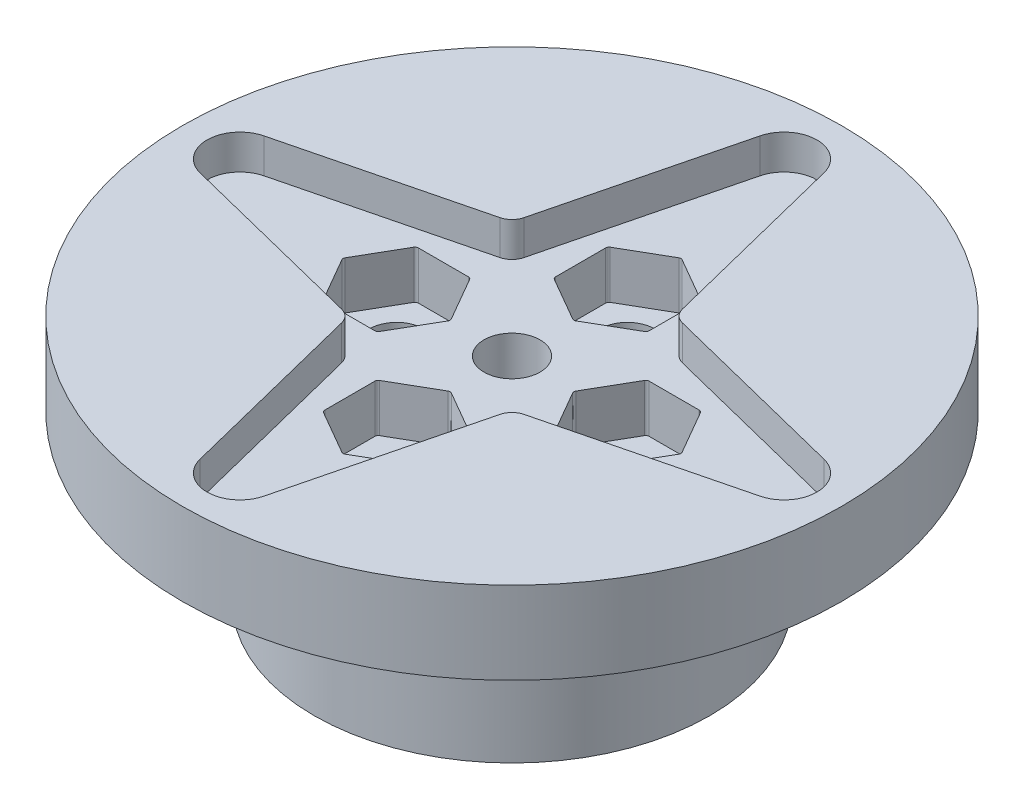
from build123d import *

# Parameters (mm, degrees)
SKETCH1_R                                       = 12
SKETCH1_R_2                                     = 1.65
BOSS_EXTRUDE1_DEPTH                             = 15
SKETCH2_R                                       = 20
SKETCH2_R_2                                     = 11.285963192
BOSS_EXTRUDE2_DEPTH                             = 5
SKETCH3_R                                       = 20
BOSS_EXTRUDE3_DEPTH                             = 3
CUT_EXTRUDE2_DEPTH                              = 2.1
SKETCH6_R                                       = 1.65
CUT_EXTRUDE3_DEPTH                              = 24.1
FILLET1_R                                       = 1
SKETCH7_R                                       = 3.5
CUT_EXTRUDE4_DEPTH                              = 5.5
CSK_FOR_M3_FLAT_HEAD_MACHINE_SCREW1_D           = 3.4
CSK_FOR_M3_FLAT_HEAD_MACHINE_SCREW1_CSINK_D     = 6.3
CSK_FOR_M3_FLAT_HEAD_MACHINE_SCREW1_CSINK_ANGLE = 90
CUT_EXTRUDE6_DEPTH                              = 2
CUT_EXTRUDE6_DEPTH_BACK                         = 10


with BuildPart() as part:
    # Sketch1 → Boss-Extrude1 (new body)
    with BuildSketch(Plane(origin=(0, 0, 0), x_dir=(1, 0, 0), z_dir=(0, 1, 0))):
        Circle(SKETCH1_R)
        with Locations((0, 7)):
            Circle(SKETCH1_R_2, mode=Mode.SUBTRACT)
        with Locations((7, 0)):
            Circle(SKETCH1_R_2, mode=Mode.SUBTRACT)
        Circle(SKETCH1_R_2, mode=Mode.SUBTRACT)
        with Locations((0, -7)):
            Circle(SKETCH1_R_2, mode=Mode.SUBTRACT)
        with Locations((-7, 0)):
            Circle(SKETCH1_R_2, mode=Mode.SUBTRACT)
    extrude(amount=BOSS_EXTRUDE1_DEPTH)

    # Sketch2 → Boss-Extrude2 (add)
    with BuildSketch(Plane(origin=(0, 15, 0), x_dir=(1, 0, 0), z_dir=(0, 1, 0))):
        Circle(SKETCH2_R)
        Circle(SKETCH2_R_2, mode=Mode.SUBTRACT)
    extrude(amount=-BOSS_EXTRUDE2_DEPTH)

    # Sketch3 → Boss-Extrude3 (add)
    with BuildSketch(Plane(origin=(0, 15, 0), x_dir=(1, 0, 0), z_dir=(0, 1, 0))):
        Circle(SKETCH3_R)
    extrude(amount=-BOSS_EXTRUDE3_DEPTH)

    # Sketch4 → Cut-Extrude2 (cut)
    with BuildSketch(Plane.XZ.offset(-15)):
        with BuildLine():
            Line((4.949747468, 4.949747468), (1.940261042, 16.98516707))
            ThreePointArc((1.940261042, 16.98516707), (0, 18.5), (-1.940261043, 16.98516707))
            Line((-1.940261043, 16.98516707), (-4.949747468, 4.949747468))
            Line((-4.949747468, 4.949747468), (-16.98516707, 1.940261042))
            ThreePointArc((-16.98516707, 1.940261042), (-18.5, 0), (-16.98516707, -1.940261043))
            Line((-16.98516707, -1.940261043), (-4.949747468, -4.949747468))
            Line((-4.949747468, -4.949747468), (-1.940261042, -16.98516707))
            ThreePointArc((-1.940261042, -16.98516707), (0, -18.5), (1.940261043, -16.98516707))
            Line((1.940261043, -16.98516707), (4.949747468, -4.949747468))
            Line((4.949747468, -4.949747468), (16.98516707, -1.940261042))
            ThreePointArc((16.98516707, -1.940261042), (18.5, 0), (16.98516707, 1.940261043))
            Line((16.98516707, 1.940261043), (4.949747468, 4.949747468))
        make_face()
    extrude(amount=CUT_EXTRUDE2_DEPTH, mode=Mode.SUBTRACT)

    # Sketch6 → Cut-Extrude3 (cut)
    with BuildSketch(Plane.XZ):
        Circle(SKETCH6_R)
    extrude(amount=-CUT_EXTRUDE3_DEPTH, mode=Mode.SUBTRACT)

    # Fillet1
    fillet1_edges = [part.edges().sort_by_distance(p)[0] for p in [
        (4.949747468, 13.95, 4.949747468),
        (-4.949747468, 13.95, 4.949747468),
        (-4.949747468, 13.95, -4.949747468),
        (4.949747468, 13.95, -4.949747468),
    ]]
    fillet(fillet1_edges, radius=FILLET1_R)

    # Sketch7 → Cut-Extrude4 (cut)
    with BuildSketch(Plane.XZ):
        Circle(SKETCH7_R)
    extrude(amount=-CUT_EXTRUDE4_DEPTH, mode=Mode.SUBTRACT)

    # CSK for M3 Flat Head Machine Screw1 (through all)
    with Locations(Plane(origin=(0, 5.5, 0), x_dir=(-1, 0, 0), z_dir=(0, -1, 0))):
        with Locations((0, 0)):
            CounterSinkHole(CSK_FOR_M3_FLAT_HEAD_MACHINE_SCREW1_D / 2, CSK_FOR_M3_FLAT_HEAD_MACHINE_SCREW1_CSINK_D / 2, counter_sink_angle=CSK_FOR_M3_FLAT_HEAD_MACHINE_SCREW1_CSINK_ANGLE)

    # Sketch12 → Cut-Extrude6 (cut, two sides)
    with BuildSketch(Plane.XZ.offset(-12)) as cut_extrude6_sk:
        with BuildLine():
            Line((-2.836233197, 8.522029946), (-2.836233197, 5.477970054))
            ThreePointArc((-2.836233197, 5.477970054), (-2.809438278, 5.377970054), (-2.736233197, 5.304764973))
            Line((-2.736233197, 5.304764973), (-0.1, 3.782735027))
            ThreePointArc((-0.1, 3.782735027), (0, 3.755940108), (0.1, 3.782735027))
            Line((0.1, 3.782735027), (2.736233197, 5.304764973))
            ThreePointArc((2.736233197, 5.304764973), (2.809438278, 5.377970054), (2.836233197, 5.477970054))
            Line((2.836233197, 5.477970054), (2.836233197, 8.522029946))
            ThreePointArc((2.836233197, 8.522029946), (2.809438278, 8.622029946), (2.736233197, 8.695235027))
            Line((2.736233197, 8.695235027), (0.1, 10.217264973))
            ThreePointArc((0.1, 10.217264973), (0, 10.244059892), (-0.1, 10.217264973))
            Line((-0.1, 10.217264973), (-2.736233197, 8.695235027))
            ThreePointArc((-2.736233197, 8.695235027), (-2.809438278, 8.622029946), (-2.836233197, 8.522029946))
        make_face()
        with BuildLine():
            Line((-10.217264973, -0.1), (-8.695235027, -2.736233197))
            ThreePointArc((-8.695235027, -2.736233197), (-8.622029946, -2.809438278), (-8.522029946, -2.836233197))
            Line((-8.522029946, -2.836233197), (-5.477970054, -2.836233197))
            ThreePointArc((-5.477970054, -2.836233197), (-5.377970054, -2.809438278), (-5.304764973, -2.736233197))
            Line((-5.304764973, -2.736233197), (-3.782735027, -0.1))
            ThreePointArc((-3.782735027, -0.1), (-3.755940108, 0), (-3.782735027, 0.1))
            Line((-3.782735027, 0.1), (-5.304764973, 2.736233197))
            ThreePointArc((-5.304764973, 2.736233197), (-5.377970054, 2.809438278), (-5.477970054, 2.836233197))
            Line((-5.477970054, 2.836233197), (-8.522029946, 2.836233197))
            ThreePointArc((-8.522029946, 2.836233197), (-8.622029946, 2.809438278), (-8.695235027, 2.736233197))
            Line((-8.695235027, 2.736233197), (-10.217264973, 0.1))
            ThreePointArc((-10.217264973, 0.1), (-10.244059892, 0), (-10.217264973, -0.1))
        make_face()
        with BuildLine():
            Line((8.522029946, 2.836233197), (5.477970054, 2.836233197))
            ThreePointArc((5.477970054, 2.836233197), (5.377970054, 2.809438278), (5.304764973, 2.736233197))
            Line((5.304764973, 2.736233197), (3.782735027, 0.1))
            ThreePointArc((3.782735027, 0.1), (3.755940108, 0), (3.782735027, -0.1))
            Line((3.782735027, -0.1), (5.304764973, -2.736233197))
            ThreePointArc((5.304764973, -2.736233197), (5.377970054, -2.809438278), (5.477970054, -2.836233197))
            Line((5.477970054, -2.836233197), (8.522029946, -2.836233197))
            ThreePointArc((8.522029946, -2.836233197), (8.622029946, -2.809438278), (8.695235027, -2.736233197))
            Line((8.695235027, -2.736233197), (10.217264973, -0.1))
            ThreePointArc((10.217264973, -0.1), (10.244059892, 0), (10.217264973, 0.1))
            Line((10.217264973, 0.1), (8.695235027, 2.736233197))
            ThreePointArc((8.695235027, 2.736233197), (8.622029946, 2.809438278), (8.522029946, 2.836233197))
        make_face()
        with BuildLine():
            Line((2.836233197, -8.522029946), (2.836233197, -5.477970054))
            ThreePointArc((2.836233197, -5.477970054), (2.809438278, -5.377970054), (2.736233197, -5.304764973))
            Line((2.736233197, -5.304764973), (0.1, -3.782735027))
            ThreePointArc((0.1, -3.782735027), (0, -3.755940108), (-0.1, -3.782735027))
            Line((-0.1, -3.782735027), (-2.736233197, -5.304764973))
            ThreePointArc((-2.736233197, -5.304764973), (-2.809438278, -5.377970054), (-2.836233197, -5.477970054))
            Line((-2.836233197, -5.477970054), (-2.836233197, -8.522029946))
            ThreePointArc((-2.836233197, -8.522029946), (-2.809438278, -8.622029946), (-2.736233197, -8.695235027))
            Line((-2.736233197, -8.695235027), (-0.1, -10.217264973))
            ThreePointArc((-0.1, -10.217264973), (0, -10.244059892), (0.1, -10.217264973))
            Line((0.1, -10.217264973), (2.736233197, -8.695235027))
            ThreePointArc((2.736233197, -8.695235027), (2.809438278, -8.622029946), (2.836233197, -8.522029946))
        make_face()
    extrude(amount=CUT_EXTRUDE6_DEPTH, mode=Mode.SUBTRACT)
    extrude(cut_extrude6_sk.sketch, amount=-CUT_EXTRUDE6_DEPTH_BACK, mode=Mode.SUBTRACT)


solid = part.part
